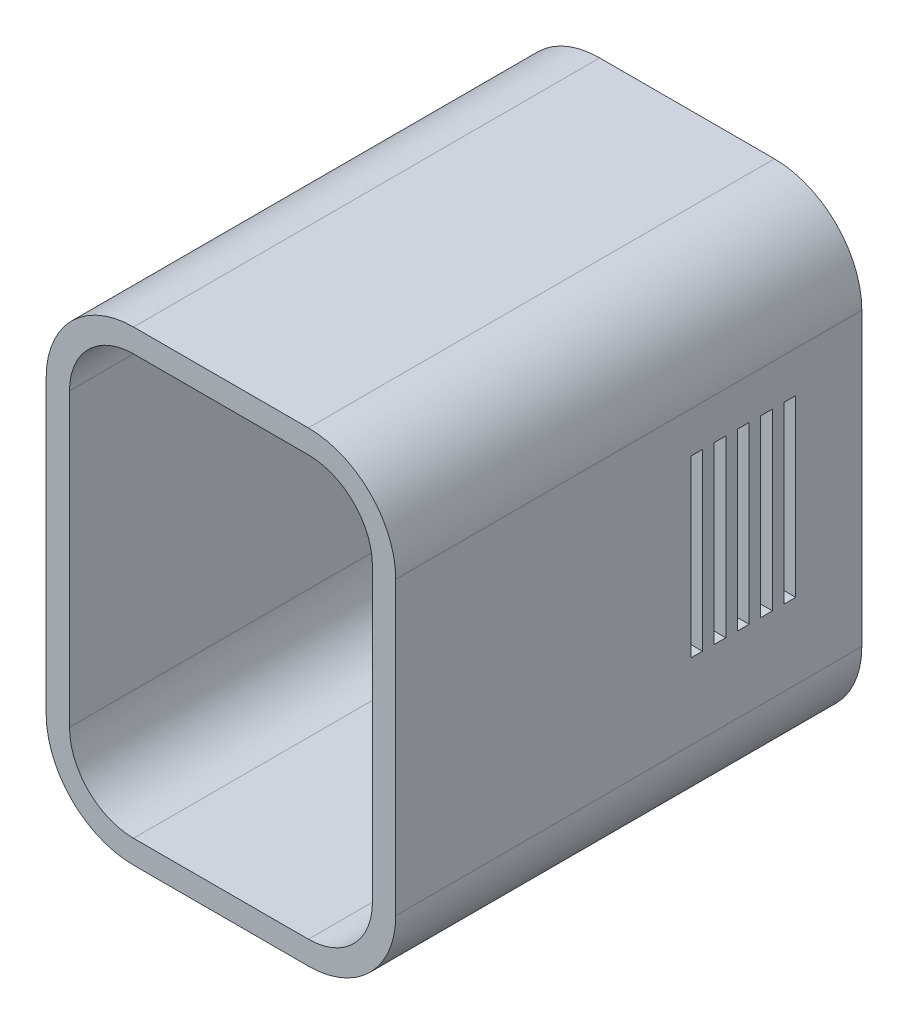
from build123d import *

# Parameters (mm, degrees)
BOSS_EXTRUDE1_DEPTH     = 40
SHELL1_T                = -2
SKETCH2_W               = 1.5
SKETCH2_H               = 6.3
SKETCH2_W_2             = 2.058506146
SKETCH2_H_2             = 3.660298136
CUT_EXTRUDE1_DEPTH      = 25
SKETCH3_W               = 1
SKETCH3_H               = 15
CUT_EXTRUDE2_DEPTH      = 1
CUT_EXTRUDE2_DEPTH_BACK = 31


with BuildPart() as part:
    # Sketch1 → Boss-Extrude1 (new body)
    with BuildSketch(Plane.XY):
        with BuildLine():
            Line((-7.5, -20), (7.5, -20))
            ThreePointArc((7.5, -20), (12.803300859, -17.803300859), (15, -12.5))
            Line((15, -12.5), (15, 12.5))
            ThreePointArc((15, 12.5), (12.803300859, 17.803300859), (7.5, 20))
            Line((7.5, 20), (-7.5, 20))
            ThreePointArc((-7.5, 20), (-12.803300859, 17.803300859), (-15, 12.5))
            Line((-15, 12.5), (-15, -12.5))
            ThreePointArc((-15, -12.5), (-12.803300859, -17.803300859), (-7.5, -20))
        make_face()
    extrude(amount=BOSS_EXTRUDE1_DEPTH)

    # Shell1
    shell1_openings = [part.faces().sort_by_distance(p)[0] for p in [
        (0, 0, 40),
    ]]
    offset(amount=SHELL1_T, openings=shell1_openings, kind=Kind.INTERSECTION)

    # Sketch2 → Cut-Extrude1 (cut)
    with BuildSketch(Plane(origin=(0, 0, 0), x_dir=(-1, 0, 0), z_dir=(0, 0, -1))):
        with Locations((-5.6, 4.85)):
            Rectangle(SKETCH2_W, SKETCH2_H)
        with Locations((7.1, 4.85)):
            Rectangle(SKETCH2_W, SKETCH2_H)
        with Locations((0.75, -7.05)):
            Rectangle(SKETCH2_W_2, SKETCH2_H_2)
    extrude(amount=-CUT_EXTRUDE1_DEPTH, mode=Mode.SUBTRACT)

    # Sketch3 → Cut-Extrude2 (cut, two sides)
    with BuildSketch(Plane.ZY.offset(15)) as cut_extrude2_sk:
        with Locations((8.174979933, 1.491514735)):
            Rectangle(SKETCH3_W, SKETCH3_H)
        with Locations((6.174979933, 1.491514735)):
            Rectangle(SKETCH3_W, SKETCH3_H)
        with Locations((10.174979933, 1.491514735)):
            Rectangle(SKETCH3_W, SKETCH3_H)
        with Locations((12.174979933, 1.491514735)):
            Rectangle(SKETCH3_W, SKETCH3_H)
        with Locations((14.174979933, 1.491514735)):
            Rectangle(SKETCH3_W, SKETCH3_H)
    extrude(amount=CUT_EXTRUDE2_DEPTH, mode=Mode.SUBTRACT)
    extrude(cut_extrude2_sk.sketch, amount=-CUT_EXTRUDE2_DEPTH_BACK, mode=Mode.SUBTRACT)


solid = part.part
